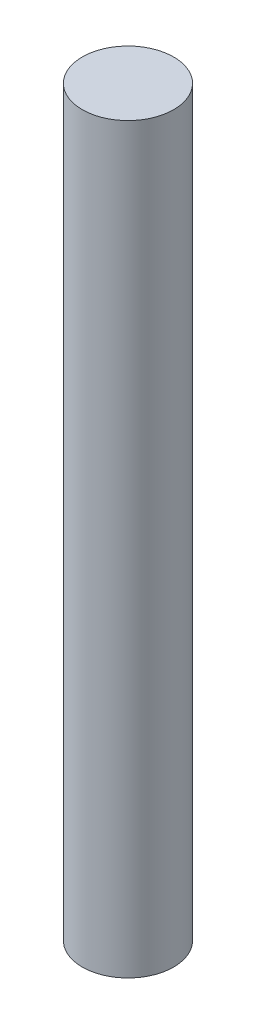
from build123d import *

# Parameters (mm, degrees)
SKETCH1_R           = 4
BOSS_EXTRUDE1_DEPTH = 65


with BuildPart() as part:
    # Sketch1 → Boss-Extrude1 (new body)
    with BuildSketch(Plane(origin=(0, 0, 0), x_dir=(1, 0, 0), z_dir=(0, 1, 0))):
        Circle(SKETCH1_R)
    extrude(amount=BOSS_EXTRUDE1_DEPTH)


solid = part.part
